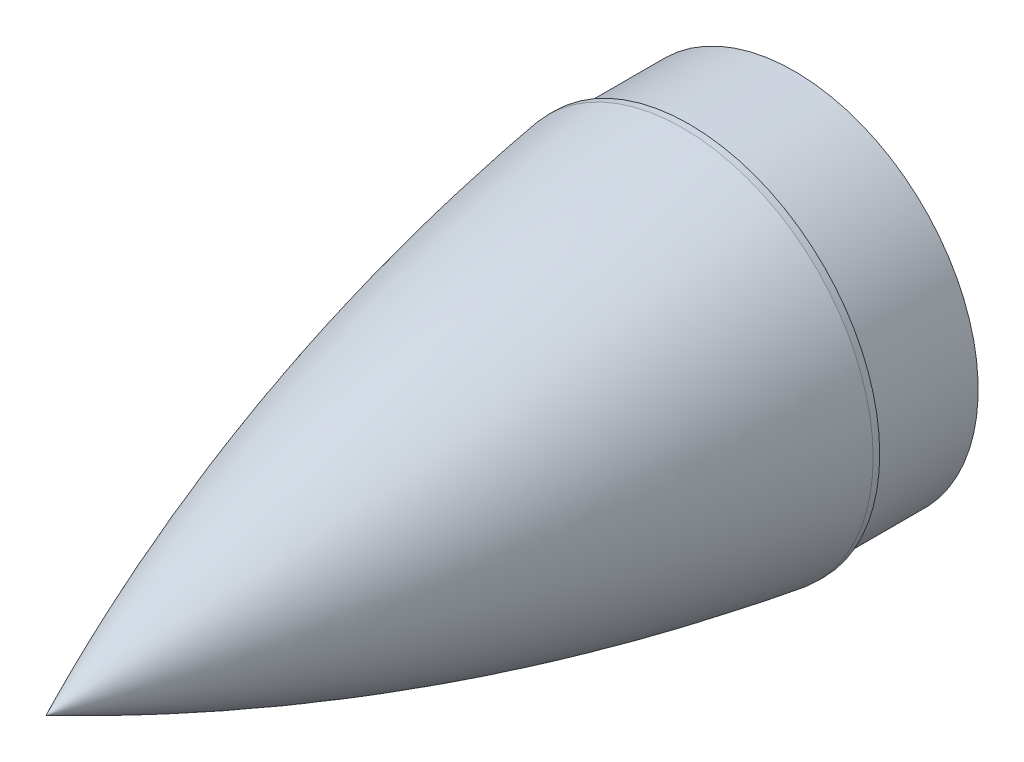
from build123d import *

# Parameters (mm, degrees)
SKETCH1_R           = 92.075
BOSS_EXTRUDE1_DEPTH = 3.175
SKETCH2_R           = 88.9
BOSS_EXTRUDE2_DEPTH = 50.8
SKETCH3_R           = 85.725
CUT_EXTRUDE1_DEPTH  = 50.8


with BuildPart() as part:
    # Sketch1 → Boss-Extrude1 (new body)
    with BuildSketch(Plane.XY):
        Circle(SKETCH1_R)
    extrude(amount=-BOSS_EXTRUDE1_DEPTH)

    # Sketch2 → Boss-Extrude2 (add)
    with BuildSketch(Plane(origin=(0, 0, -3.175), x_dir=(-1, 0, 0), z_dir=(0, 0, -1))):
        Circle(SKETCH2_R)
    extrude(amount=BOSS_EXTRUDE2_DEPTH)

    # Sketch3 → Cut-Extrude1 (cut)
    with BuildSketch(Plane(origin=(0, 0, -53.975), x_dir=(-1, 0, 0), z_dir=(0, 0, -1))):
        Circle(SKETCH3_R)
    extrude(amount=-CUT_EXTRUDE1_DEPTH, mode=Mode.SUBTRACT)

    # Sketch4 → Revolve1 (revolve)
    with BuildSketch(Plane(origin=(0, 0, 0), x_dir=(1, 0, 0), z_dir=(0, 1, 0))):
        with BuildLine():
            add(Edge.make_bspline(
                [(0, -304.8), (65.277515516, -157.994281663), (88.9, 0)],
                knots=[0, 0, 0, 1, 1, 1], degree=2))
            Line((88.9, 0), (92.075, 0))
            add(Edge.make_bspline(
                [(0, -307.975), (68.538261276, -160.143028223), (92.075, 0)],
                knots=[0, 0, 0, 1, 1, 1], degree=2))
            Line((0, -307.975), (0, -304.8))
        make_face()
    revolve(axis=Axis((0, 0, 0), (0, 0, 1)))


solid = part.part
